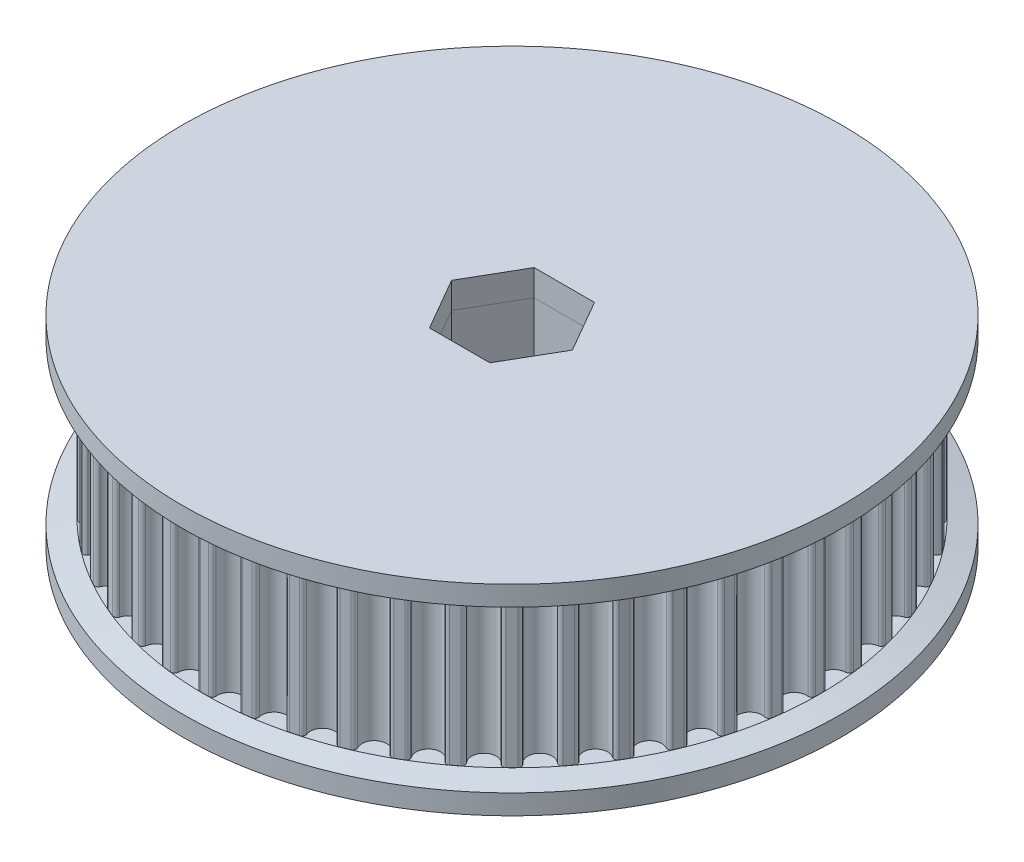
from build123d import *

# Parameters (mm, degrees)
SKETCH1_R           = 38.197186369
BOSS_EXTRUDE1_DEPTH = 21.175
CUT_EXTRUDE3_START  = 3.175
CUT_EXTRUDE3_DEPTH  = 18
CIRPATTERN4_COUNT   = 48
SKETCH8_R           = 40.005
BOSS_EXTRUDE3_DEPTH = 3.175
BOSS_EXTRUDE4_START = 21.175
SKETCH8_2_R         = 40.005
BOSS_EXTRUDE4_DEPTH = 3.175
CHAMFER1_SIZE       = 0.762
CHAMFER1_SIZE2      = 2.657409806
CHAMFER2_SIZE       = 0.762
CHAMFER2_SIZE2      = 2.657409806


with BuildPart() as part:
    # Sketch1 → Boss-Extrude1 (new body)
    with BuildSketch(Plane(origin=(0, 0, 0), x_dir=(1, 0, 0), z_dir=(0, 1, 0))):
        Circle(SKETCH1_R)
        Polygon((7.332348419, 0), (3.666174209, 6.35), (-3.666174209, 6.35), (-7.332348419, 0), (-3.666174209, -6.35), (3.666174209, -6.35), align=None, mode=Mode.SUBTRACT)
    extrude(amount=BOSS_EXTRUDE1_DEPTH)

    # Sketch5 → Cut-Extrude3 (cut)
    with BuildSketch(Plane(origin=(0, 0, 0), x_dir=(1, 0, 0), z_dir=(0, 1, 0)).offset(CUT_EXTRUDE3_START)):
        with BuildLine():
            ThreePointArc((0, 39.197186369), (2.563618646, 39.113262184), (5.116259482, 38.861849006))
            Line((5.116259482, 38.861849006), (4.872175503, 37.007847115))
            ThreePointArc((4.872175503, 37.007847115), (4.623239832, 37.039769109), (4.374095158, 37.070016641))
            ThreePointArc((4.374095158, 37.070016641), (4.041004706, 36.966984738), (3.893780195, 36.650931315))
            ThreePointArc((3.893780195, 36.650931315), (2.306584348, 35.191676616), (0.92343814, 36.845617819))
            ThreePointArc((0.92343814, 36.845617819), (0.818726406, 37.178184016), (0.50193395, 37.323811495))
            ThreePointArc((0.50193395, 37.323811495), (0.250972648, 37.326342641), (0, 37.327186369))
            Line((0, 37.327186369), (0, 39.197186369))
        make_face()
    cut_extrude3 = extrude(amount=CUT_EXTRUDE3_DEPTH, mode=Mode.SUBTRACT)

    # CirPattern4: Cut-Extrude3 ×48 about axis
    cirpattern4_axis = Axis((0, 0, 0), (0, 1, 0))
    for i in range(1, CIRPATTERN4_COUNT):
        add(cut_extrude3.rotate(cirpattern4_axis, i * 360 / CIRPATTERN4_COUNT), mode=Mode.SUBTRACT)

    # Sketch8 → Boss-Extrude3 (add)
    with BuildSketch(Plane(origin=(0, 0, 0), x_dir=(1, 0, 0), z_dir=(0, 1, 0))):
        Circle(SKETCH8_R)
        Polygon((7.332348419, 0), (3.666174209, 6.35), (-3.666174209, 6.35), (-7.332348419, 0), (-3.666174209, -6.35), (3.666174209, -6.35), align=None, mode=Mode.SUBTRACT)
    extrude(amount=BOSS_EXTRUDE3_DEPTH)

    # Chamfer1
    chamfer1_edges = [part.edges().sort_by_distance(p)[0] for p in [
        (-40.005, 3.175, 0),
    ]]
    chamfer1_side = [part.faces().sort_by_distance(p)[0] for p in [
        (-40.005, 1.5875, 0),
    ]]
    chamfer(chamfer1_edges, length=CHAMFER1_SIZE, length2=CHAMFER1_SIZE2, reference=chamfer1_side[0])


with BuildPart() as body_2:
    # Sketch8_2 → Boss-Extrude4 (new body)
    with BuildSketch(Plane(origin=(0, 0, 0), x_dir=(1, 0, 0), z_dir=(0, 1, 0)).offset(BOSS_EXTRUDE4_START)):
        Circle(SKETCH8_2_R)
        Polygon((7.332348419, 0), (3.666174209, 6.35), (-3.666174209, 6.35), (-7.332348419, 0), (-3.666174209, -6.35), (3.666174209, -6.35), align=None, mode=Mode.SUBTRACT)
    extrude(amount=BOSS_EXTRUDE4_DEPTH)

    # Chamfer2
    chamfer2_edges = [body_2.edges().sort_by_distance(p)[0] for p in [
        (-40.005, 21.175, 0),
    ]]
    chamfer2_side = [body_2.faces().sort_by_distance(p)[0] for p in [
        (-40.005, 22.7625, 0),
    ]]
    chamfer(chamfer2_edges, length=CHAMFER2_SIZE, length2=CHAMFER2_SIZE2, reference=chamfer2_side[0])


solid = Compound([part.part, body_2.part])
